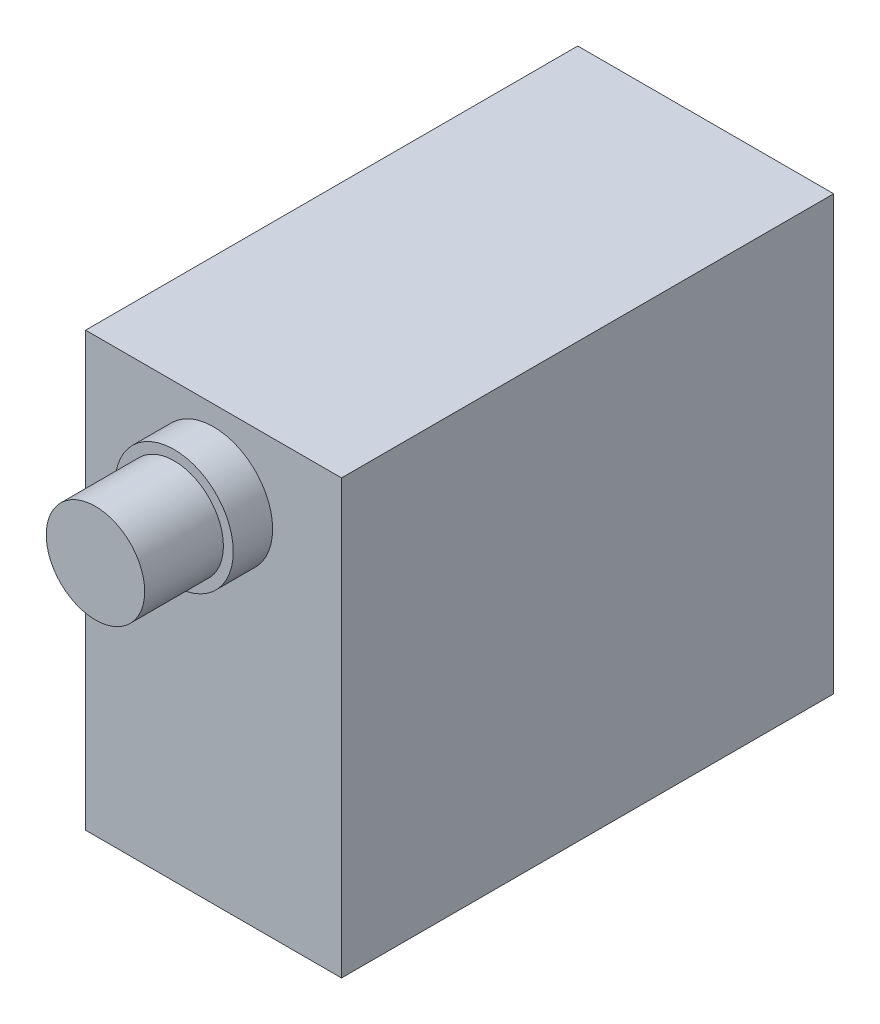
from build123d import *

# Parameters (mm, degrees)
SKETCH1_W           = 13
SKETCH1_H           = 22
BOSS_EXTRUDE1_DEPTH = 25
SKETCH2_R           = 3
BOSS_EXTRUDE2_DEPTH = 2
SKETCH3_R           = 2.5
BOSS_EXTRUDE3_DEPTH = 4


with BuildPart() as part:
    # Sketch1 → Boss-Extrude1 (new body)
    with BuildSketch(Plane.XY):
        Rectangle(SKETCH1_W, SKETCH1_H)
    extrude(amount=BOSS_EXTRUDE1_DEPTH)

    # Sketch2 → Boss-Extrude2 (add)
    with BuildSketch(Plane.XY.offset(25)):
        with Locations((0, 7)):
            Circle(SKETCH2_R)
    extrude(amount=BOSS_EXTRUDE2_DEPTH)

    # Sketch3 → Boss-Extrude3 (add)
    with BuildSketch(Plane.XY.offset(27)):
        with Locations((0, 7)):
            Circle(SKETCH3_R)
    extrude(amount=BOSS_EXTRUDE3_DEPTH)


solid = part.part
